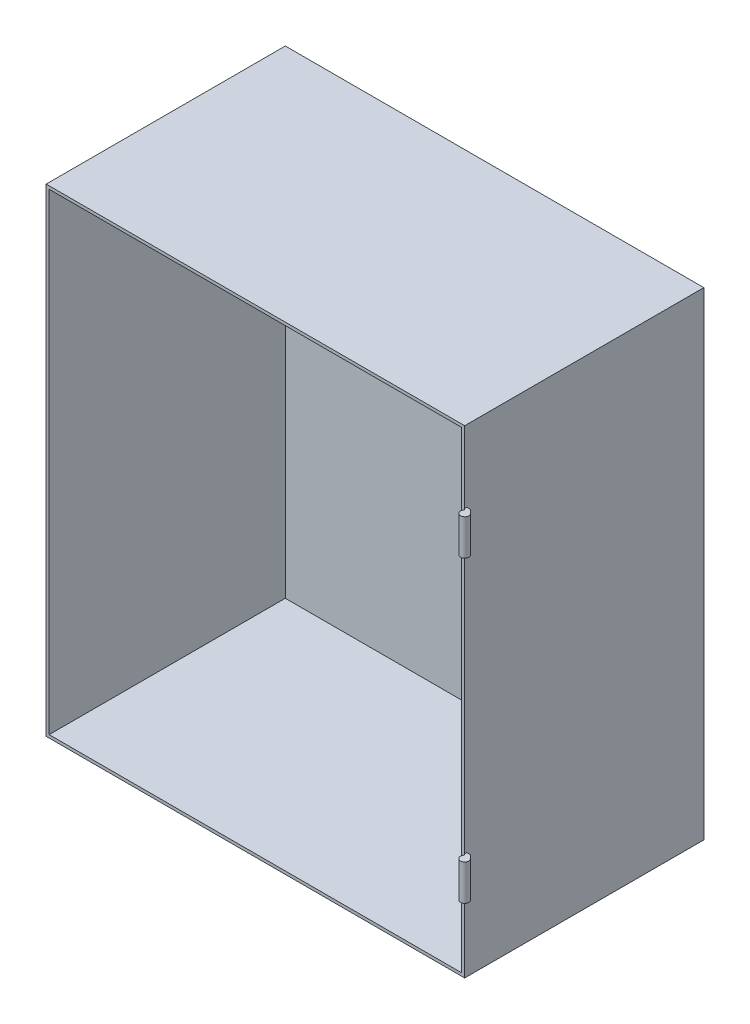
from build123d import *

# Parameters (mm, degrees)
CROQUIS1_W              = 700
CROQUIS1_H              = 800
SALIENTE_EXTRUIR1_DEPTH = 400
CROQUIS2_W              = 690
CROQUIS2_H              = 790
CORTAR_EXTRUIR1_DEPTH   = 395
SALIENTE_EXTRUIR2_DEPTH = 800
CROQUIS4_W              = 56.686989083
CROQUIS4_H              = 120
CROQUIS4_H_2            = 440
CORTAR_EXTRUIR2_DEPTH   = 450


with BuildPart() as part:
    # Croquis1 → Saliente-Extruir1 (new body)
    with BuildSketch(Plane.XY):
        with Locations((350, -400)):
            Rectangle(CROQUIS1_W, CROQUIS1_H)
    extrude(amount=SALIENTE_EXTRUIR1_DEPTH)

    # Croquis2 → Cortar-Extruir1 (cut)
    with BuildSketch(Plane.XY.offset(400)):
        with Locations((350, -400)):
            Rectangle(CROQUIS2_W, CROQUIS2_H)
    extrude(amount=-CORTAR_EXTRUIR1_DEPTH, mode=Mode.SUBTRACT)

    # Croquis3 → Saliente-Extruir2 (add)
    with BuildSketch(Plane(origin=(0, 0, 0), x_dir=(1, 0, 0), z_dir=(0, 1, 0))):
        with BuildLine():
            Line((700, -396.545914708), (706, -396.545914708))
            Line((706, -396.545914708), (710.25902772, -400.804942428))
            ThreePointArc((710.25902772, -400.804942428), (708.049920297, -413.920814068), (702.050252532, -402.050252532))
            Line((702.050252532, -402.050252532), (700, -400))
            Line((700, -400), (700, -396.545914708))
        make_face()
    extrude(amount=-SALIENTE_EXTRUIR2_DEPTH)

    # Croquis4 → Cortar-Extruir2 (cut)
    with BuildSketch(Plane(origin=(0, 0, 0), x_dir=(-1, 0, 0), z_dir=(0, 0, -1))):
        with Locations((-728.343494542, -60)):
            Rectangle(CROQUIS4_W, CROQUIS4_H)
        with Locations((-728.343494542, -740)):
            Rectangle(CROQUIS4_W, CROQUIS4_H)
        with Locations((-728.343494542, -400)):
            Rectangle(CROQUIS4_W, CROQUIS4_H_2)
    extrude(amount=-CORTAR_EXTRUIR2_DEPTH, mode=Mode.SUBTRACT)


solid = part.part
